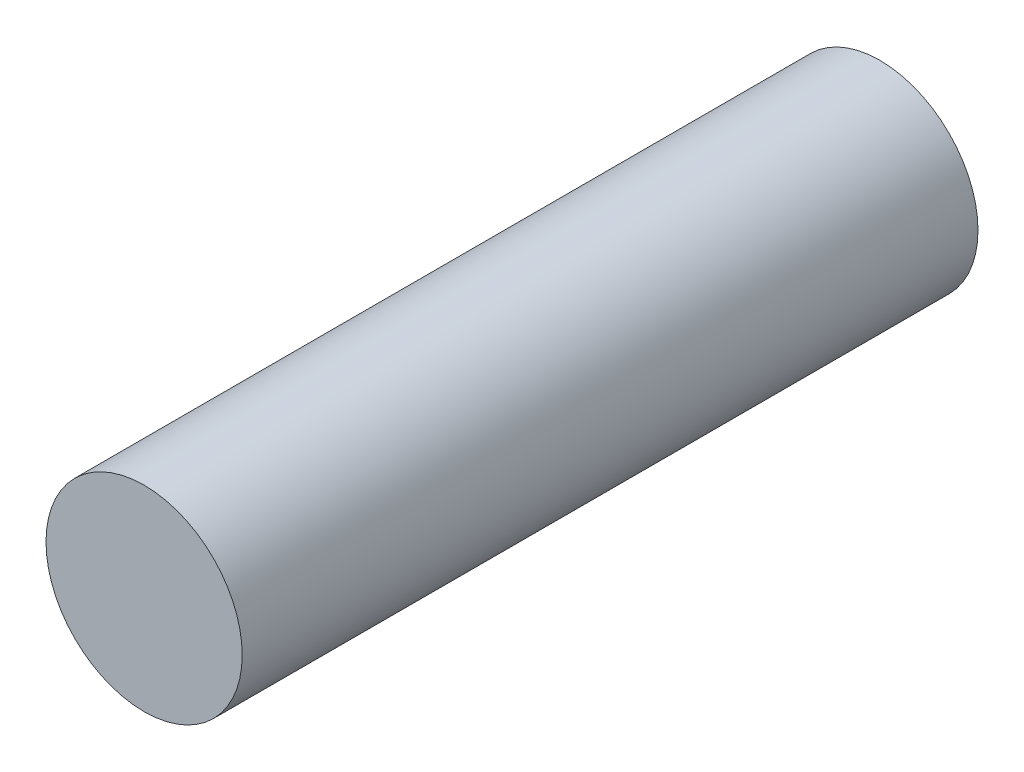
from build123d import *

# Parameters (mm, degrees)
SKETCH1_R           = 4
BOSS_EXTRUDE1_DEPTH = 30


with BuildPart() as part:
    # Sketch1 → Boss-Extrude1 (new body)
    with BuildSketch(Plane.XY):
        Circle(SKETCH1_R)
    extrude(amount=BOSS_EXTRUDE1_DEPTH)


solid = part.part
